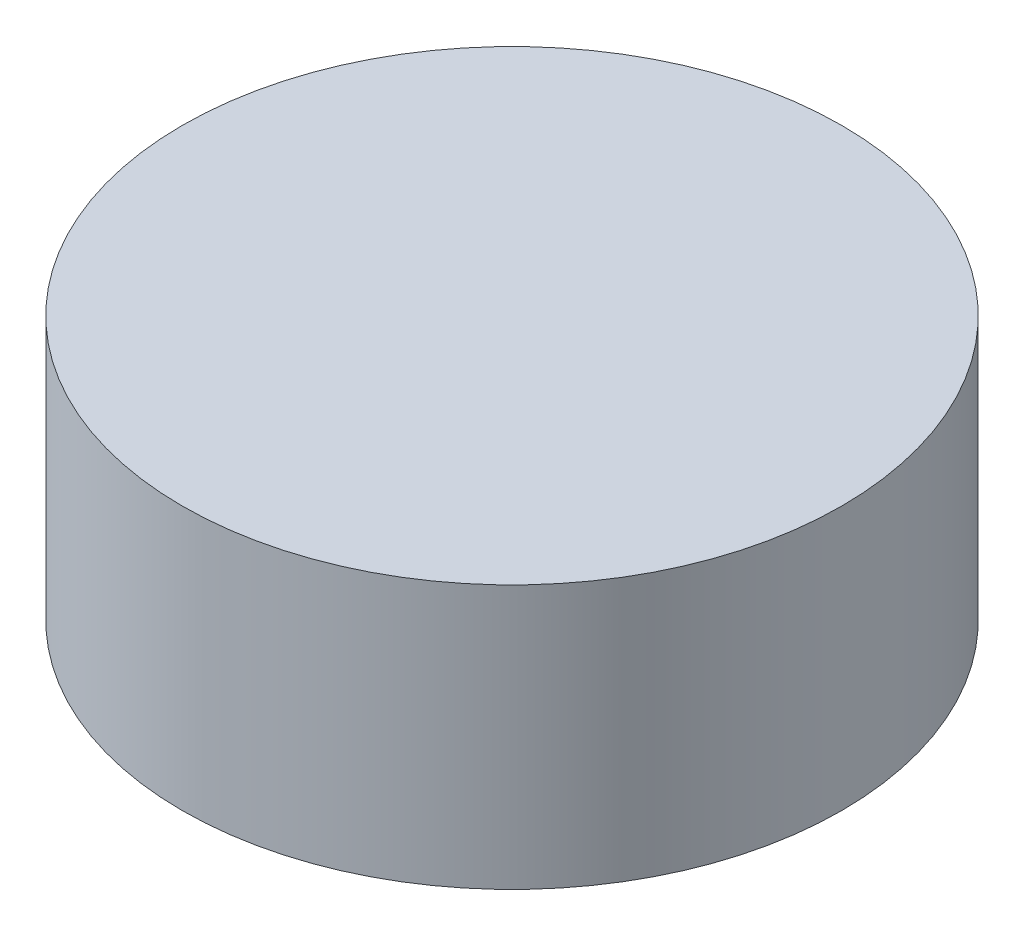
from build123d import *

# Parameters (mm, degrees)
ESQUISSE1_R        = 25
BOSS_EXTRU_1_DEPTH = 10


with BuildPart() as part:
    # Esquisse1 → Boss.-Extru.1 (new body, symmetric)
    with BuildSketch(Plane(origin=(0, 0, 0), x_dir=(1, 0, 0), z_dir=(0, 1, 0))):
        Circle(ESQUISSE1_R)
    extrude(amount=BOSS_EXTRU_1_DEPTH, both=True)


solid = part.part
